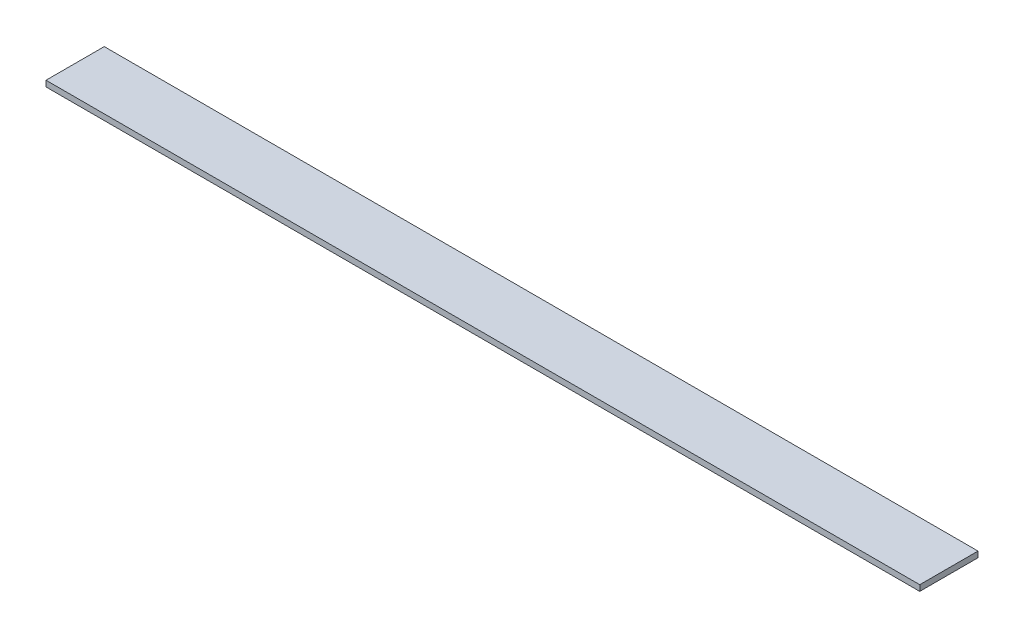
from build123d import *

# Parameters (mm, degrees)
SKETCH_1_W      = 450
SKETCH_1_H      = 30
EXTRUDE_1_DEPTH = 3


with BuildPart() as part:
    # Эскиз1 → Бобышка-Вытянуть1 (new body)
    with BuildSketch(Plane(origin=(0, 0, 0), x_dir=(1, 0, 0), z_dir=(0, 1, 0))):
        with Locations((225, 15)):
            Rectangle(SKETCH_1_W, SKETCH_1_H)
    extrude(amount=EXTRUDE_1_DEPTH)


solid = part.part
